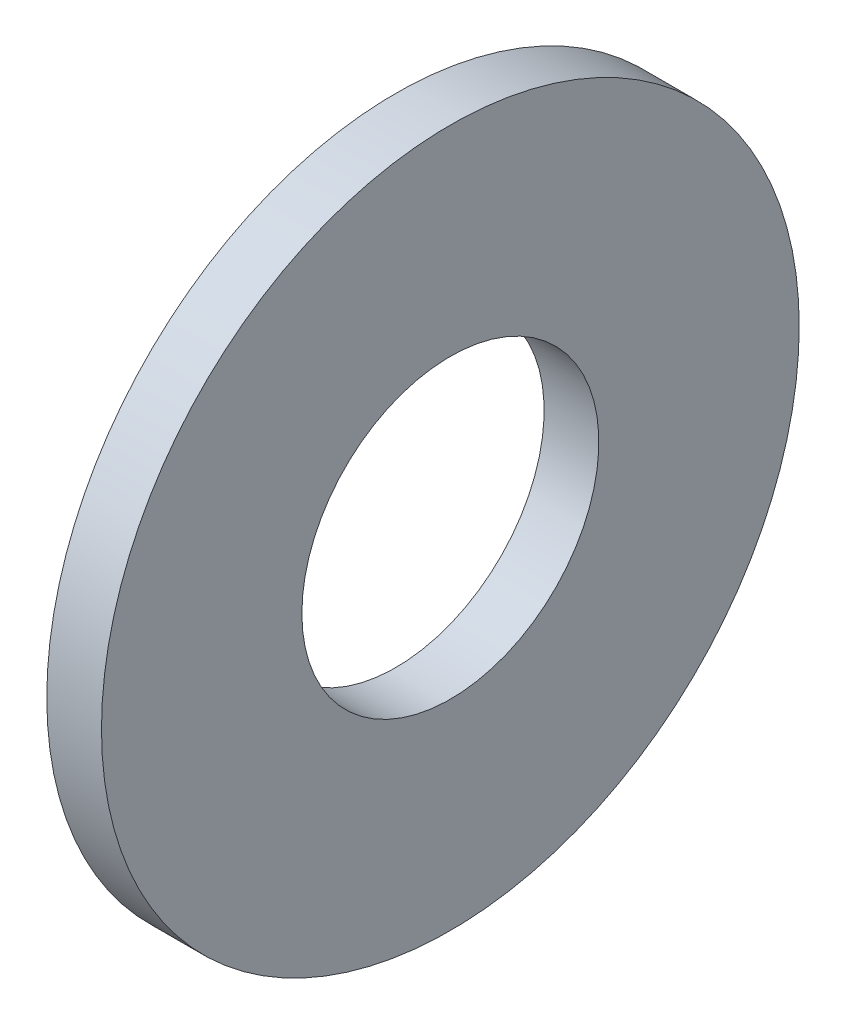
from build123d import *

# Parameters (mm, degrees)
SKETCH1_W = 1.2446
SKETCH1_H = 4.5593


with BuildPart() as part:
    # Sketch1 → Base-Revolve (revolve)
    with BuildSketch(Plane.XY):
        with Locations((-0.6223, 5.65785)):
            Rectangle(SKETCH1_W, SKETCH1_H)
    revolve(axis=Axis((-34.925, 0, 0), (1, 0, 0)))


solid = part.part
